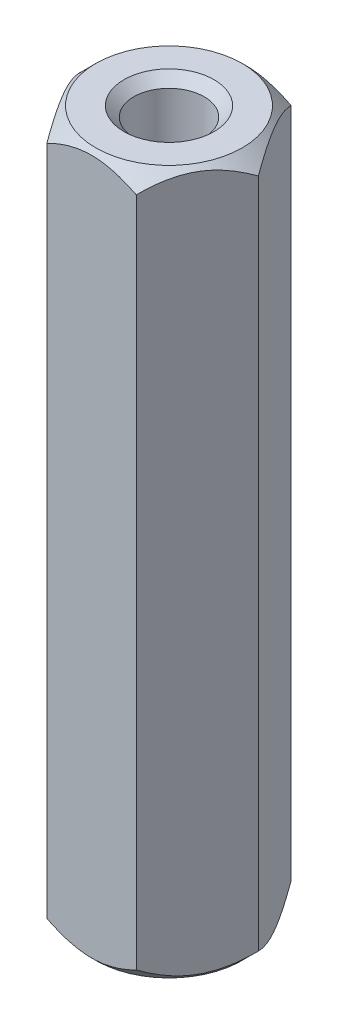
from build123d import *

# Parameters (mm, degrees)
BOSS_EXTRUDE1_DEPTH = 25


with BuildPart() as part:
    # Sketch1 → Boss-Extrude1 (new body)
    with BuildSketch(Plane(origin=(0, 0, 0), x_dir=(1, 0, 0), z_dir=(0, 1, 0))):
        Polygon((1.58771324, 2.75), (-1.58771324, 2.75), (-3.175426481, 0), (-1.58771324, -2.75), (1.58771324, -2.75), (3.175426481, 0), align=None)
    extrude(amount=BOSS_EXTRUDE1_DEPTH)

    # Sketch2 → M3 Tapped Hole1 (revolve, cut)
    with BuildSketch(Plane(origin=(0, 25, 0), x_dir=(0, 0, 1), z_dir=(1, 0, 0))):
        Polygon((0, 0), (0, 25), (1.6, 25), (1.25, 24.65), (1.25, 0.35), (1.6, 0), align=None)
    revolve(axis=Axis((0, 31.35, 0), (0, -1, 0)), mode=Mode.SUBTRACT)

    # Sketch4 → Cut-Revolve1 (revolve, cut)
    with BuildSketch(Plane.XY):
        Polygon((2.6, 0), (3.175426481, 0.575426481), (3.175426481, 0), align=None)
        Polygon((3.175426481, 25), (2.6, 25), (3.175426481, 24.424573519), align=None)
    revolve(axis=Axis((0, 25, 0), (0, -1, 0)), mode=Mode.SUBTRACT)


solid = part.part
